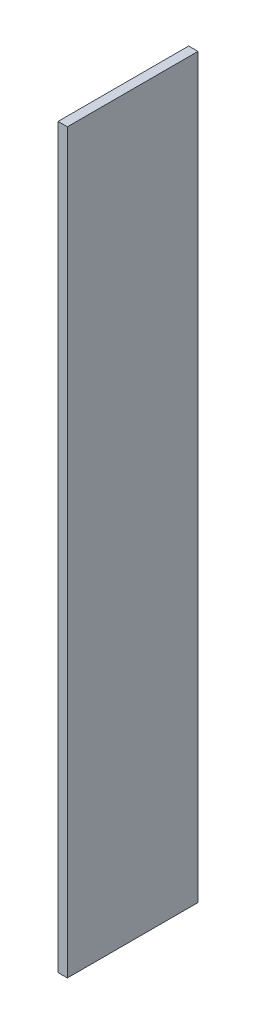
from build123d import *

# Parameters (mm, degrees)
SKETCH1_W           = 88.9
SKETCH1_H           = 501.65
BOSS_EXTRUDE1_DEPTH = 6.35


with BuildPart() as part:
    # Sketch1 → Boss-Extrude1 (new body)
    with BuildSketch(Plane(origin=(0, 0, 0), x_dir=(0, 0, -1), z_dir=(1, 0, 0))):
        with Locations((44.45, 250.825)):
            Rectangle(SKETCH1_W, SKETCH1_H)
    extrude(amount=BOSS_EXTRUDE1_DEPTH)


solid = part.part
